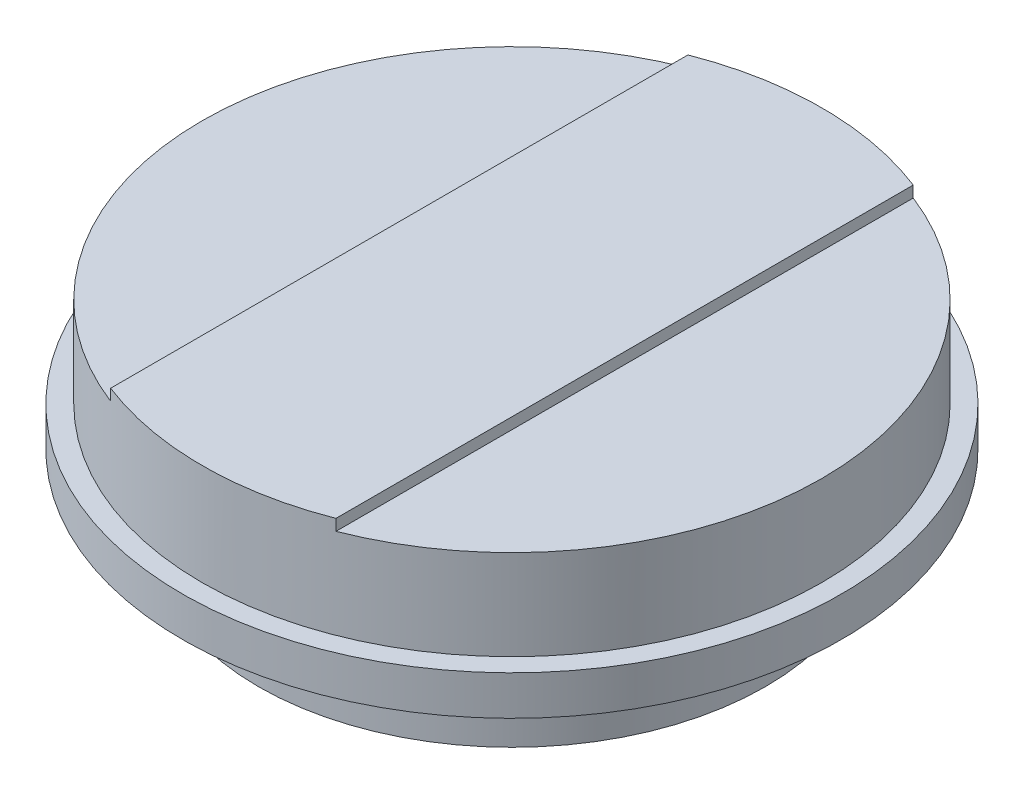
from build123d import *

# Parameters (mm, degrees)
EXTRUDE_1_DEPTH = 2


with BuildPart() as part:
    # 草圖1 → 旋轉1 (revolve)
    with BuildSketch(Plane.XY):
        Polygon((0, 0), (55, 0), (55, -16), (58.5, -16), (58.5, -23), (45, -23), (45, -37), (10, -37), (10, -57), (5, -57), (5, -39), (0, -39), align=None)
    revolve(axis=Axis((0, 84.440513305, 0), (0, -1, 0)))

    # 草圖3 → 填料-伸長1 (add)
    with BuildSketch(Plane(origin=(0, 0, 0), x_dir=(1, 0, 0), z_dir=(0, 1, 0))):
        with BuildLine():
            Line((-20, 51.23475383), (-20, -51.23475383))
            ThreePointArc((-20, -51.23475383), (0, -55), (20, -51.23475383))
            Line((20, -51.23475383), (20, 51.23475383))
            ThreePointArc((20, 51.23475383), (0, 55), (-20, 51.23475383))
        make_face()
    extrude(amount=EXTRUDE_1_DEPTH)


solid = part.part
